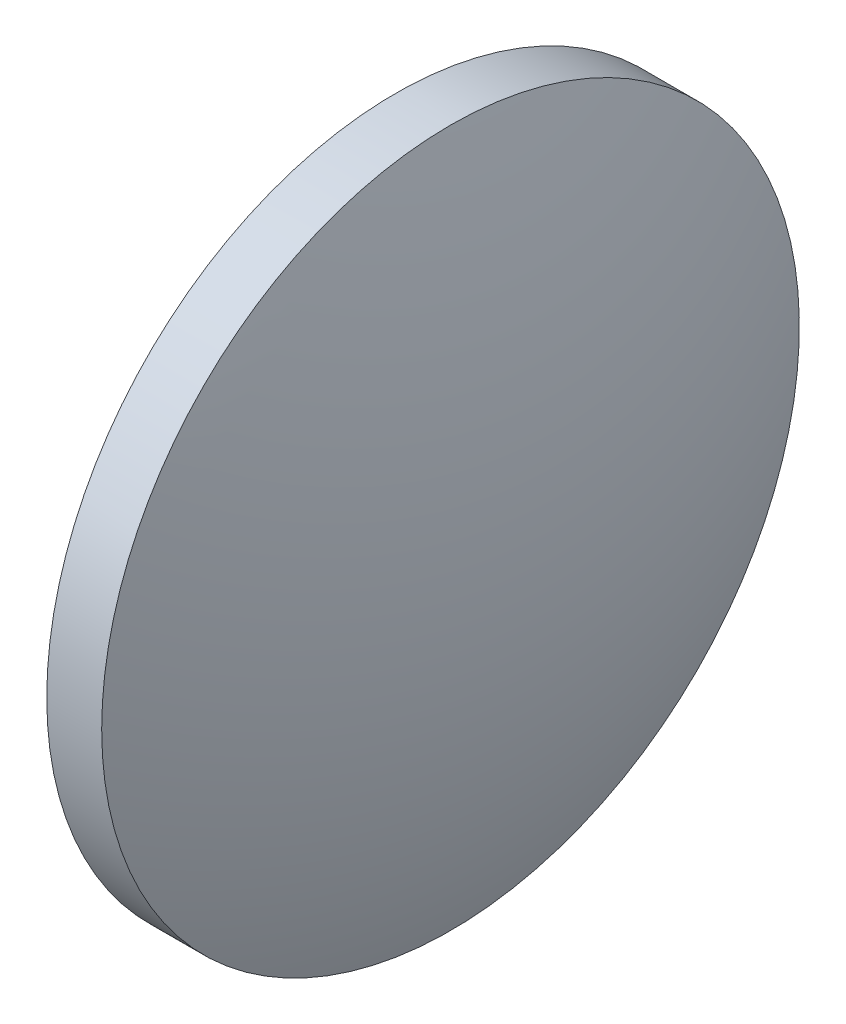
from build123d import *


with BuildPart() as part:
    # 草图1 → 旋转1 (revolve)
    with BuildSketch(Plane.XY):
        with BuildLine():
            Line((551.208250683, 132.5931626), (551.208250683, 145.2931626))
            Line((551.208250683, 145.2931626), (553.208250683, 145.2931626))
            ThreePointArc((553.208250683, 145.2931626), (555.032723098, 139.059297458), (555.648250683, 132.5931626))
            Line((555.648250683, 132.5931626), (551.208250683, 132.5931626))
        make_face()
    revolve(axis=Axis((545.503577135, 132.5931626, 0), (1, 0, 0)))


solid = part.part
